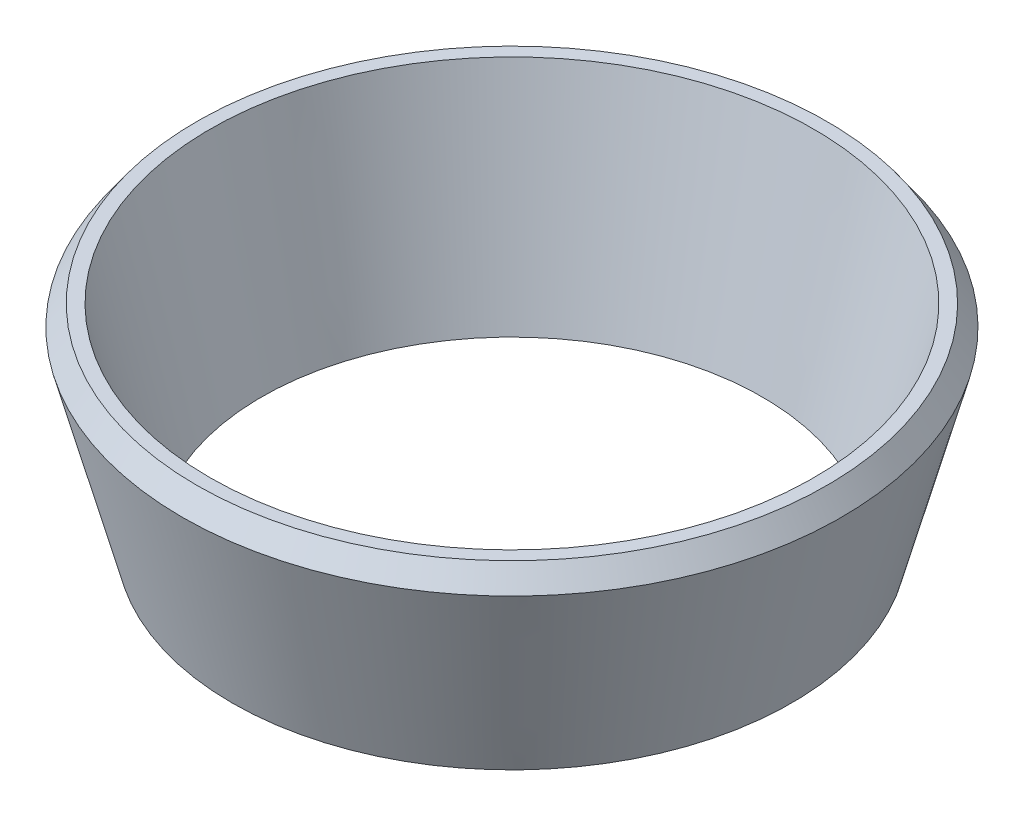
from build123d import *


with BuildPart() as part:
    # Sketch1 → Revolve1 (revolve)
    with BuildSketch(Plane.XY):
        Polygon((22.379324271, 0.757981005), (19, -11.852442091), (17, -11.852442091), (20.5, 2.147557909), (21.4, 2.147557909), align=None)
    revolve(axis=Axis((0, 93.373057912, 0), (0, -1, 0)))


solid = part.part
